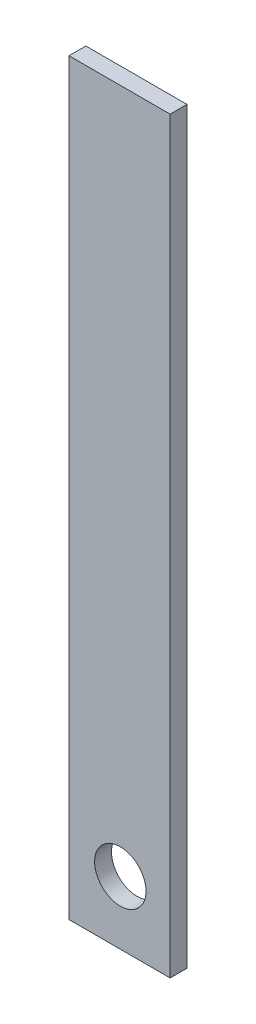
from build123d import *

# Parameters (mm, degrees)
SKETCH2_W           = 12
SKETCH2_H           = 88.764040292
SKETCH2_R           = 3.050000035
BOSS_EXTRUDE1_DEPTH = 2


with BuildPart() as part:
    # Sketch2 → Boss-Extrude1 (new body)
    with BuildSketch(Plane(origin=(0, 0, 0), x_dir=(-1, 0, 0), z_dir=(0, 0, 1))):
        with Locations((97.119796832, 229.460844267)):
            Rectangle(SKETCH2_W, SKETCH2_H)
        with Locations((97.033616752, 266.365749925)):
            Circle(SKETCH2_R, mode=Mode.SUBTRACT)
    extrude(amount=BOSS_EXTRUDE1_DEPTH)


solid = part.part
